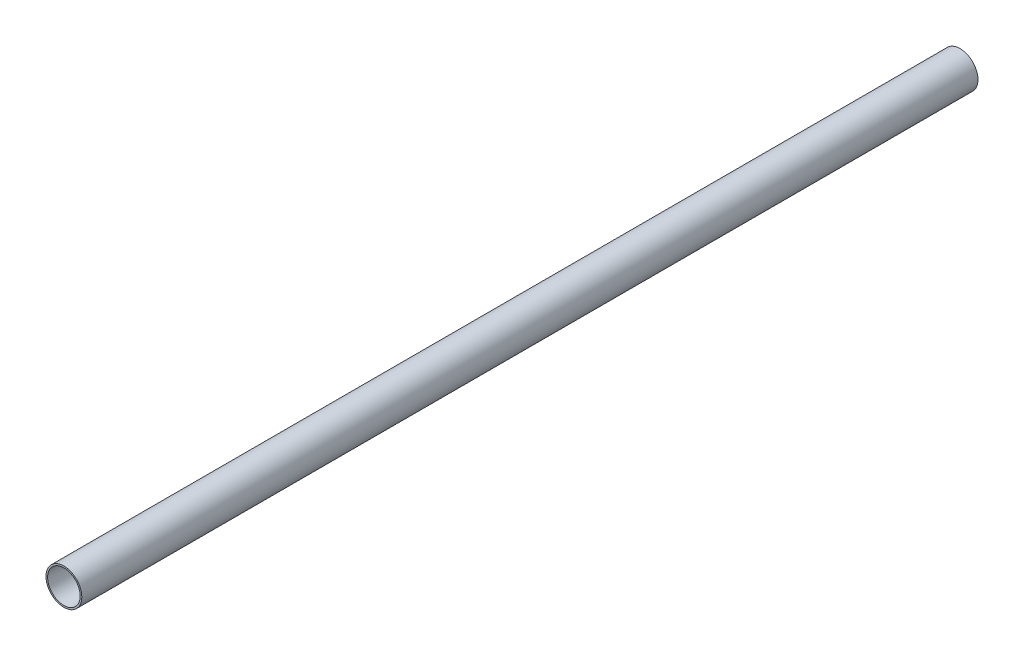
from build123d import *

# Parameters (mm, degrees)
SKETCH1_R           = 11
SKETCH1_R_2         = 10
BOSS_EXTRUDE1_DEPTH = 550


with BuildPart() as part:
    # Sketch1 → Boss-Extrude1 (new body)
    with BuildSketch(Plane.XY):
        Circle(SKETCH1_R)
        Circle(SKETCH1_R_2, mode=Mode.SUBTRACT)
    extrude(amount=BOSS_EXTRUDE1_DEPTH)


solid = part.part
